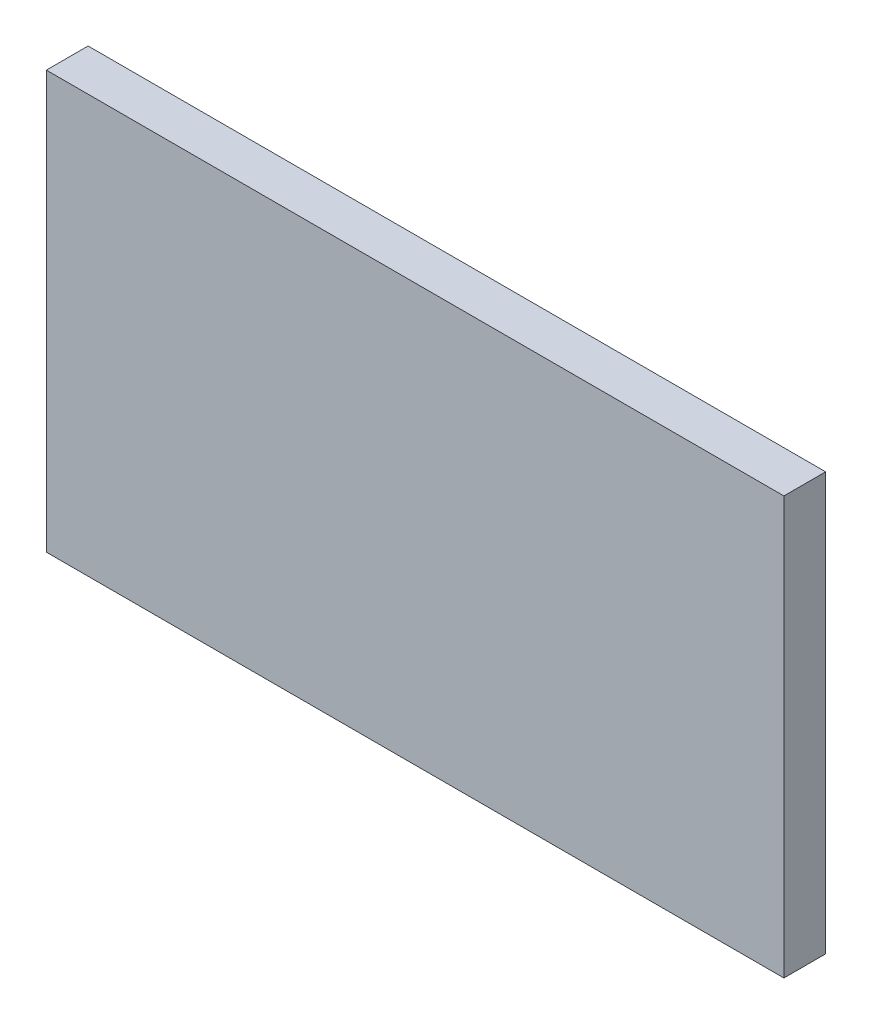
from build123d import *

# Parameters (mm, degrees)
ESQUISSE1_W        = 53
ESQUISSE1_H        = 30
BOSS_EXTRU_1_DEPTH = 3


with BuildPart() as part:
    # Esquisse1 → Boss.-Extru.1 (new body)
    with BuildSketch(Plane.XY):
        with Locations((-41.717258586, 20.819915254)):
            Rectangle(ESQUISSE1_W, ESQUISSE1_H)
    extrude(amount=BOSS_EXTRU_1_DEPTH)


solid = part.part
